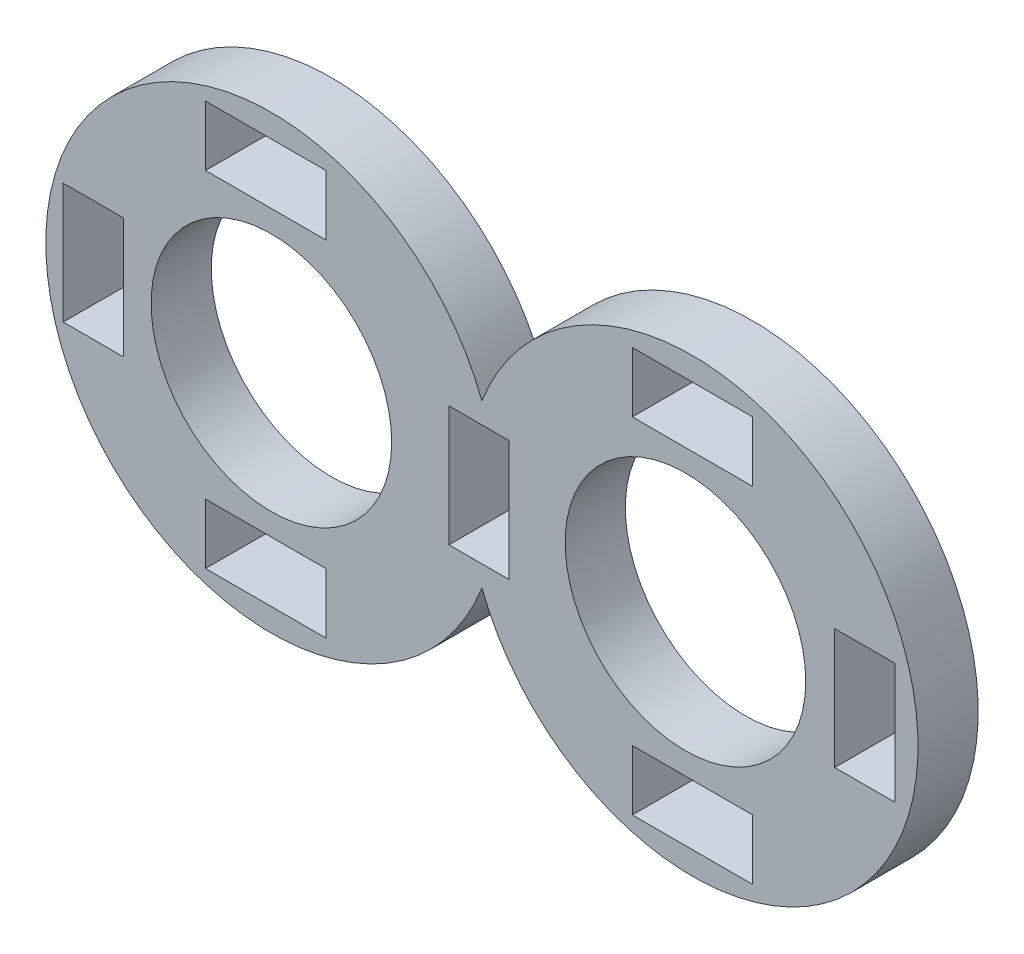
from build123d import *

# Parameters (mm, degrees)
SKETCH1_R           = 3.75
BOSS_EXTRUDE1_DEPTH = 1
SKETCH2_R           = 2
CUT_EXTRUDE3_DEPTH  = 1
SKETCH3_W           = 2
SKETCH3_H           = 1
SKETCH3_W_2         = 1
SKETCH3_H_2         = 2
CUT_EXTRUDE4_DEPTH  = 1


with BuildPart() as part:
    # Sketch1 → Boss-Extrude1 (new body)
    with BuildSketch(Plane.XY):
        Circle(SKETCH1_R)
        with Locations((7, 0)):
            Circle(SKETCH1_R)
    extrude(amount=BOSS_EXTRUDE1_DEPTH)

    # Sketch2 → Cut-Extrude3 (cut)
    with BuildSketch(Plane.XY):
        Circle(SKETCH2_R)
        with Locations((6.883478598, 0)):
            Circle(SKETCH2_R)
    extrude(amount=CUT_EXTRUDE3_DEPTH, mode=Mode.SUBTRACT)

    # Sketch3 → Cut-Extrude4 (cut)
    with BuildSketch(Plane.XY):
        with Locations((7, -2.86532029)):
            Rectangle(SKETCH3_W, SKETCH3_H)
        with Locations((9.86532029, 0)):
            Rectangle(SKETCH3_W_2, SKETCH3_H_2)
        with Locations((7, 2.86532029)):
            Rectangle(SKETCH3_W, SKETCH3_H)
        with Locations((-0.095382463, -2.86532029)):
            Rectangle(SKETCH3_W, SKETCH3_H)
        with Locations((-0.095382463, 2.86532029)):
            Rectangle(SKETCH3_W, SKETCH3_H)
        with Locations((-2.960702753, 0)):
            Rectangle(SKETCH3_W_2, SKETCH3_H_2)
        with Locations((3.452308768, 0)):
            Rectangle(SKETCH3_W_2, SKETCH3_H_2)
    extrude(amount=CUT_EXTRUDE4_DEPTH, mode=Mode.SUBTRACT)


solid = part.part
